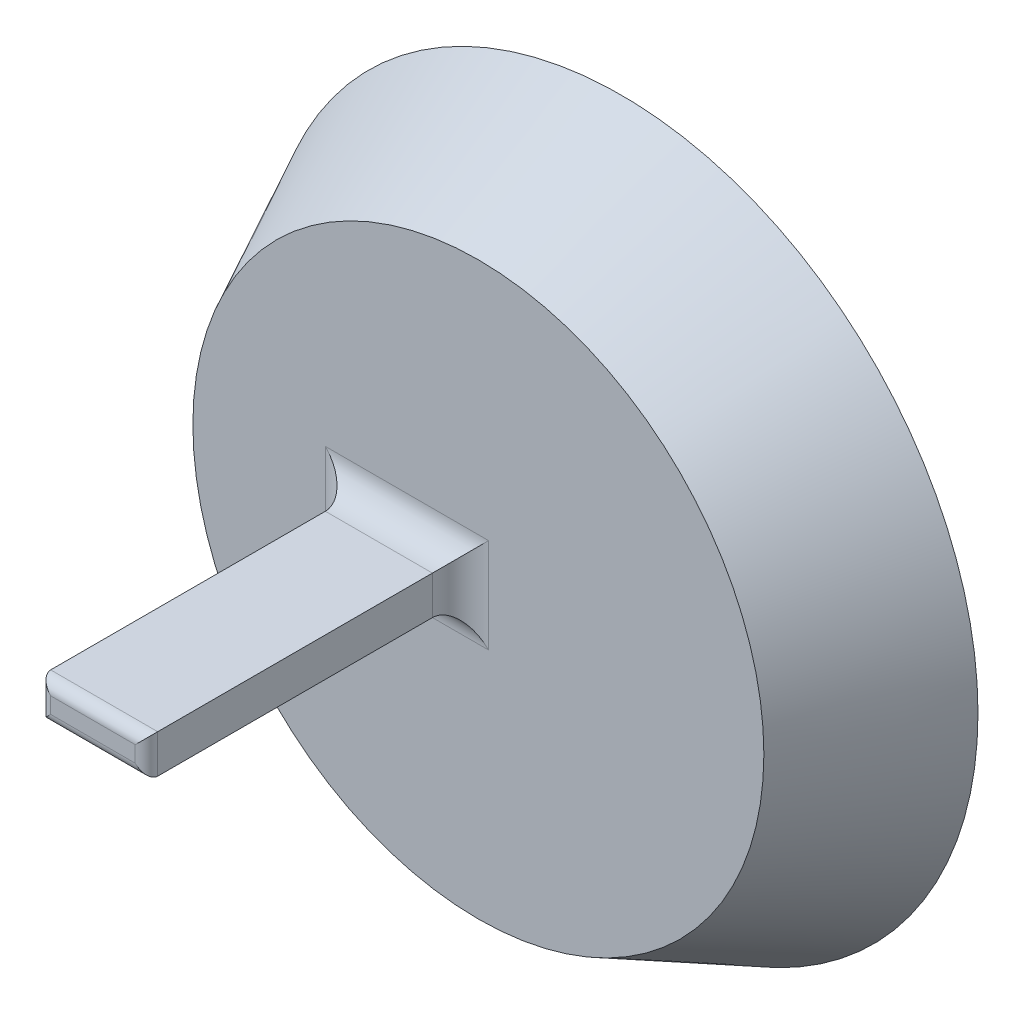
from build123d import *

# Parameters (mm, degrees)
SKETCH1_R           = 63.5
SKETCH2_R           = 50.8
SHELL1_T            = -10
SKETCH3_W           = 19.05
SKETCH3_H           = 6.858
BOSS_EXTRUDE1_DEPTH = 55.88
FILLET2_R           = 2
FILLET3_R           = 5


with BuildPart() as part:
    # Sketch1 → Loft1 section 0
    with BuildSketch(Plane.XY):
        Circle(SKETCH1_R)
    # Sketch2 → Loft1 section 1
    with BuildSketch(Plane.XY.offset(25.4)):
        Circle(SKETCH2_R)
    loft()

    # Shell1
    shell1_openings = [part.faces().sort_by_distance(p)[0] for p in [
        (0, 0, 0),
    ]]
    offset(amount=SHELL1_T, openings=shell1_openings, kind=Kind.INTERSECTION)

    # Sketch3 → Boss-Extrude1 (add)
    with BuildSketch(Plane.XY.offset(25.4)):
        with Locations((-12.7, 0)):
            Rectangle(SKETCH3_W, SKETCH3_H)
    extrude(amount=BOSS_EXTRUDE1_DEPTH)

    # Fillet2
    fillet2_edges = [part.edges().sort_by_distance(p)[0] for p in [
        (-22.225, 0, 81.28),
        (-12.7, -3.429, 81.28),
        (-3.175, 0, 81.28),
        (-12.7, 3.429, 81.28),
    ]]
    fillet(fillet2_edges, radius=FILLET2_R)

    # Fillet3
    fillet3_edges = [part.edges().sort_by_distance(p)[0] for p in [
        (-22.225, 0, 25.4),
        (-12.7, -3.429, 25.4),
        (-3.175, 0, 25.4),
        (-12.7, 3.429, 25.4),
    ]]
    fillet(fillet3_edges, radius=FILLET3_R)


solid = part.part
